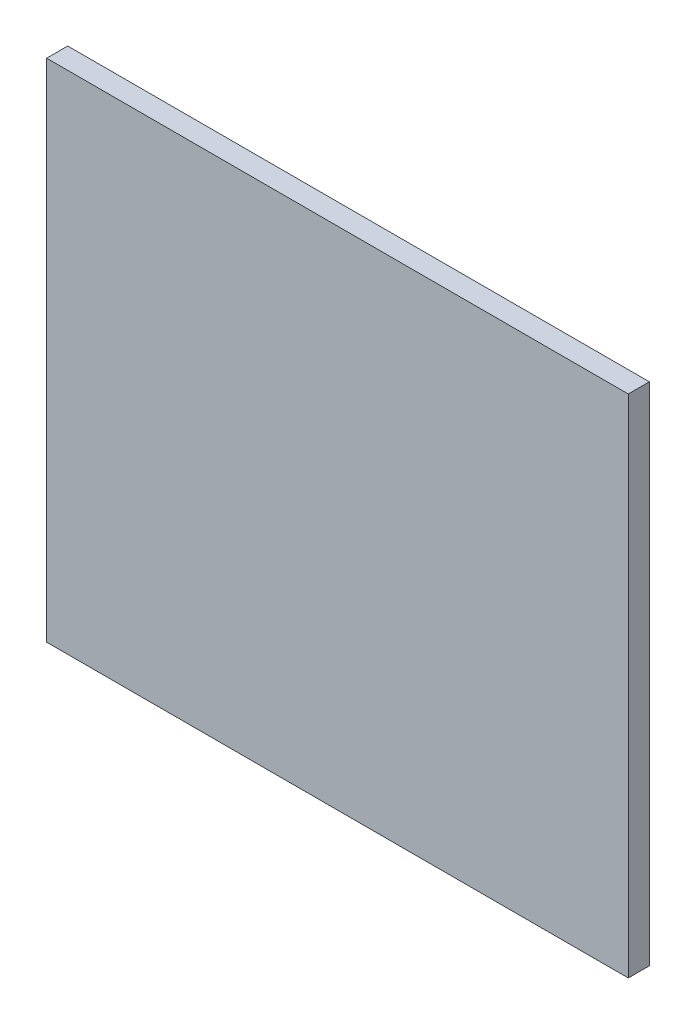
from build123d import *

# Parameters (mm, degrees)
SKETCH1_W           = 87.63
SKETCH1_H           = 76.2
BOSS_EXTRUDE1_DEPTH = 3.175


with BuildPart() as part:
    # Sketch1 → Boss-Extrude1 (new body)
    with BuildSketch(Plane.XY):
        Rectangle(SKETCH1_W, SKETCH1_H)
    extrude(amount=BOSS_EXTRUDE1_DEPTH)


solid = part.part
